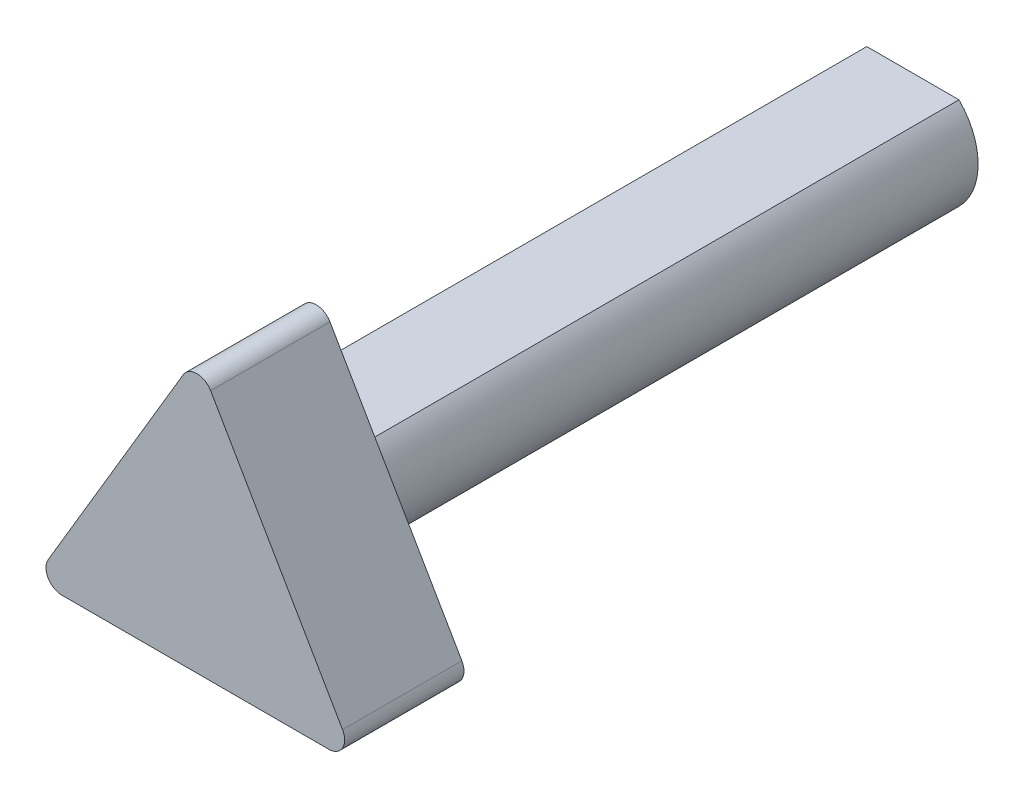
from build123d import *

# Parameters (mm, degrees)
BOSS_EXTRUDE1_DEPTH = 114.3
BOSS_EXTRUDE2_DEPTH = 19.05


with BuildPart() as part:
    # Sketch1 → Boss-Extrude1 (new body)
    with BuildSketch(Plane.XY):
        with BuildLine():
            Line((-7.359452383, -7.368165079), (7.359452383, -7.368165079))
            ThreePointArc((7.359452383, -7.368165079), (10.414, 0), (7.359452383, 7.368165079))
            Line((7.359452383, 7.368165079), (-7.359452383, 7.368165079))
            ThreePointArc((-7.359452383, 7.368165079), (-10.414, 0), (-7.359452383, -7.368165079))
        make_face()
    extrude(amount=-BOSS_EXTRUDE1_DEPTH)

    # Sketch2 → Boss-Extrude2 (add)
    with BuildSketch(Plane.XY):
        with BuildLine():
            Line((2.171966529, 21.691427715), (23.229399553, -14.6453605))
            ThreePointArc((23.229399553, -14.6453605), (23.232480647, -17.187136052), (21.031750526, -18.458914093))
            Line((21.031750526, -18.458914093), (-21.582602225, -18.458914093))
            ThreePointArc((-21.582602225, -18.458914093), (-23.789789798, -17.175863979), (-23.767109444, -14.622947964))
            Line((-23.767109444, -14.622947964), (-2.210189717, 21.713840251))
            ThreePointArc((-2.210189717, 21.713840251), (-0.012691839, 22.957840901), (2.171966529, 21.691427715))
        make_face()
    extrude(amount=-BOSS_EXTRUDE2_DEPTH)


solid = part.part
